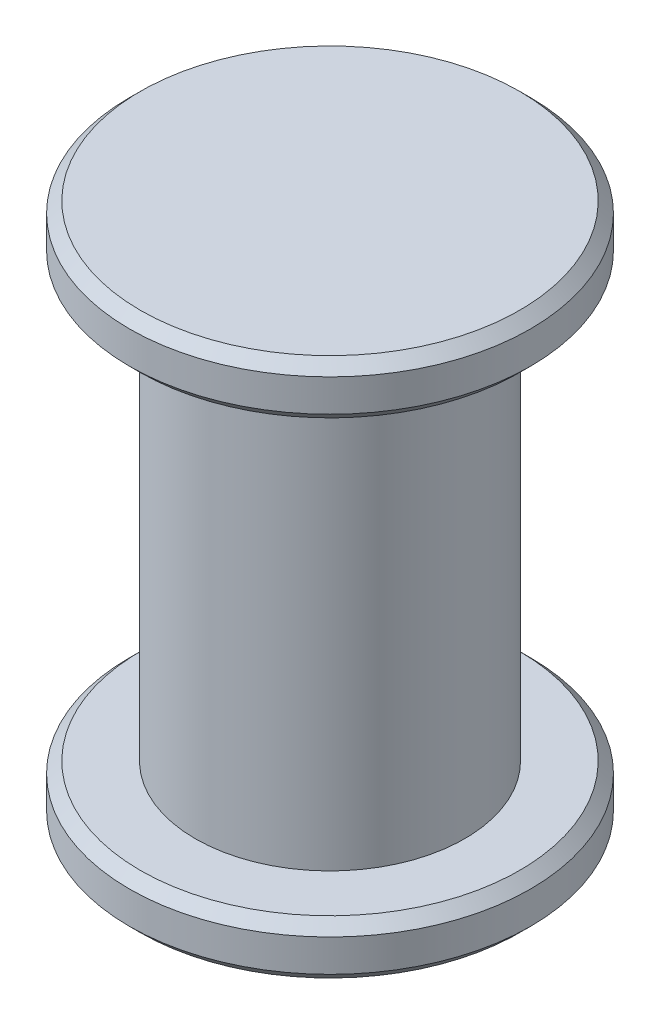
from build123d import *

# Parameters (mm, degrees)
SKETCH2_R           = 0.25
BOSS_EXTRUDE1_DEPTH = 0.8
SKETCH3_R           = 0.371871199
BOSS_EXTRUDE2_DEPTH = 0.1
SKETCH4_R           = 0.371871199
BOSS_EXTRUDE3_DEPTH = 0.1
CHAMFER1_SIZE       = 0.02
CHAMFER2_SIZE       = 0.02
CHAMFER3_SIZE       = 0.02


with BuildPart() as part:
    # Sketch2 → Boss-Extrude1 (new body)
    with BuildSketch(Plane(origin=(0, 0, 0), x_dir=(1, 0, 0), z_dir=(0, 1, 0))):
        Circle(SKETCH2_R)
    extrude(amount=BOSS_EXTRUDE1_DEPTH)

    # Sketch3 → Boss-Extrude2 (add)
    with BuildSketch(Plane(origin=(0, 0.8, 0), x_dir=(1, 0, 0), z_dir=(0, 1, 0))):
        Circle(SKETCH3_R)
    extrude(amount=BOSS_EXTRUDE2_DEPTH)

    # Sketch4 → Boss-Extrude3 (add)
    with BuildSketch(Plane.XZ):
        Circle(SKETCH4_R)
    extrude(amount=BOSS_EXTRUDE3_DEPTH)

    # Chamfer1
    chamfer1_edges = [part.edges().sort_by_distance(p)[0] for p in [
        (-0.371871199, 0.9, 0),
    ]]
    chamfer(chamfer1_edges, length=CHAMFER1_SIZE)

    # Chamfer2
    chamfer2_edges = [part.edges().sort_by_distance(p)[0] for p in [
        (-0.371871199, 0.8, 0),
        (-0.371871199, 0, 0),
    ]]
    chamfer(chamfer2_edges, length=CHAMFER2_SIZE)

    # Chamfer3
    chamfer3_edges = [part.edges().sort_by_distance(p)[0] for p in [
        (-0.371871199, -0.1, 0),
    ]]
    chamfer(chamfer3_edges, length=CHAMFER3_SIZE)


solid = part.part
